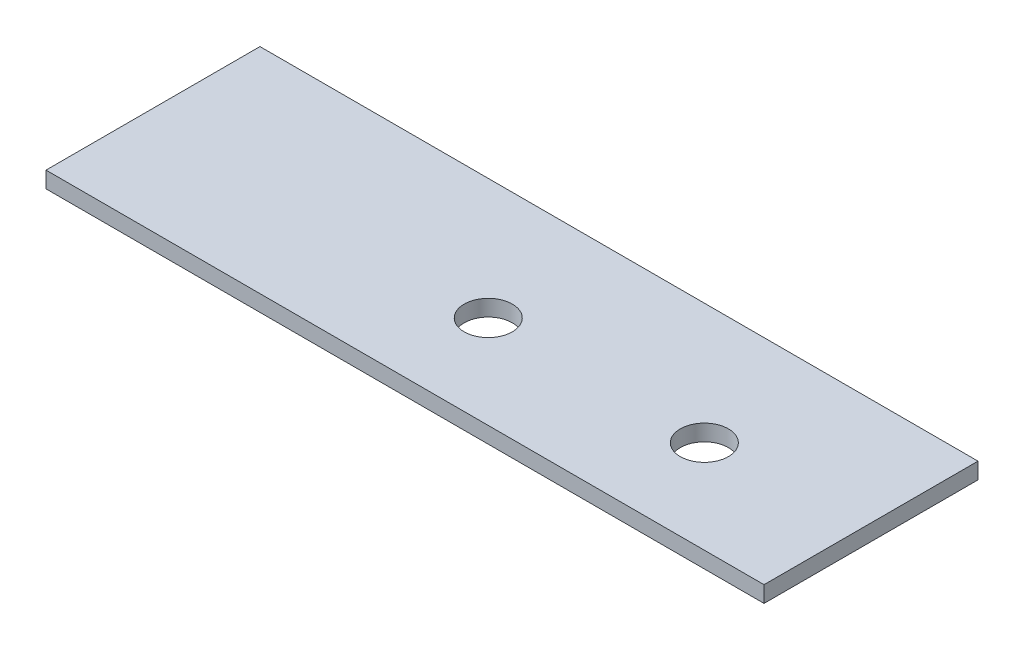
from build123d import *

# Parameters (mm, degrees)
SKETCH1_W           = 33.56
SKETCH1_H           = 10
SKETCH1_R           = 1.125
BOSS_EXTRUDE1_DEPTH = 0.38


with BuildPart() as part:
    # Sketch1 → Boss-Extrude1 (new body, symmetric)
    with BuildSketch(Plane(origin=(0, 0, 0), x_dir=(1, 0, 0), z_dir=(0, 1, 0))):
        Rectangle(SKETCH1_W, SKETCH1_H)
        with Locations(Location((-0.46, -0.65, 0), (0, 0, 270))):  # turned: the seam where the file's is
            Circle(SKETCH1_R, mode=Mode.SUBTRACT)
        with Locations(Location((9.64, -0.65, 0), (0, 0, 270))):  # turned: the seam where the file's is
            Circle(SKETCH1_R, mode=Mode.SUBTRACT)
    extrude(amount=BOSS_EXTRUDE1_DEPTH, both=True)


solid = part.part
